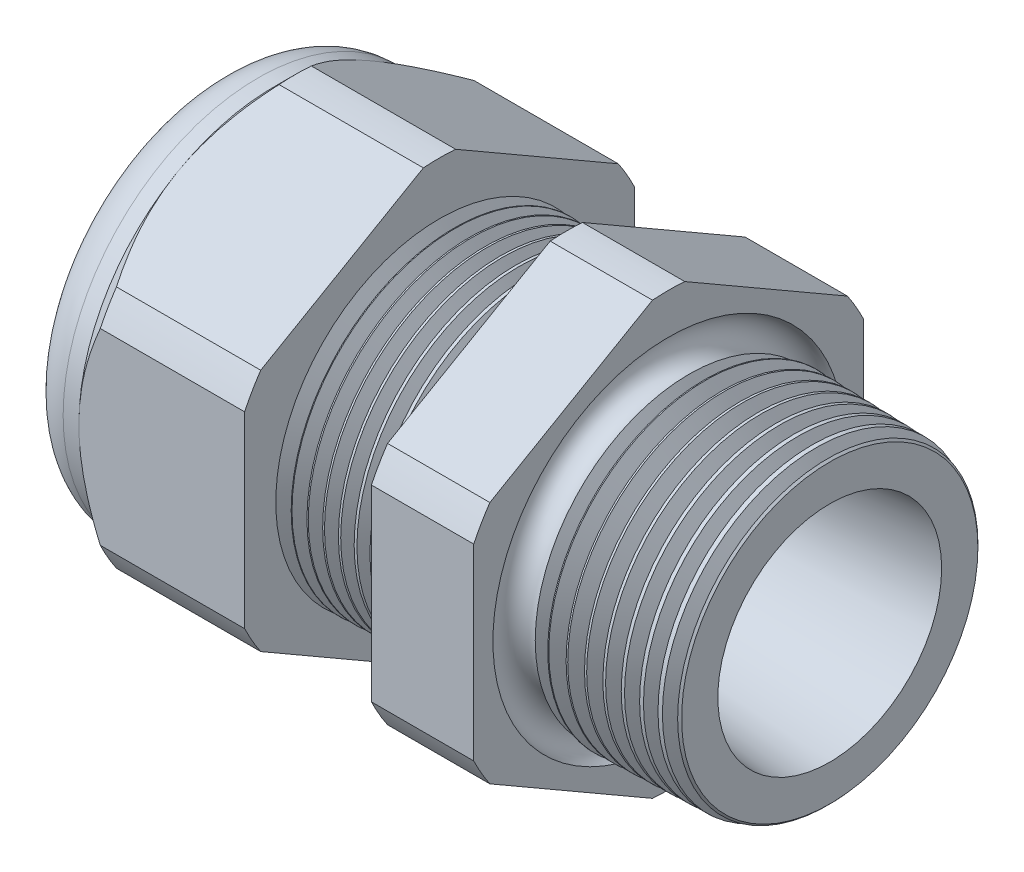
from build123d import *

# Parameters (mm, degrees)
SKETCH12_OUTSIDE_W = 52.432
SKETCH12_OUTSIDE_H = 52.432
CUT_EXTRUDE2_DEPTH = 28.172
FILLET4_R          = 2.032
SKETCH19_OUTSIDE_W = 33.316
SKETCH19_OUTSIDE_H = 35.412
SKETCH19_OUTSIDE_R = 9.525
CUT_EXTRUDE3_DEPTH = 1.999996
CUT_EXTRUDE3_DRAFT = -45
CHAMFER1_SIZE      = 0.260919487
CHAMFER1_SIZE2     = 0.254
SKETCH21_R         = 3.937
PLUG_DEPTH         = 3.81
SKETCH22_R         = 3.683
CUT_EXTRUDE4_DEPTH = 0.508
SKETCH27_R         = 0.889
PLUGHOLES_DEPTH    = 30.464
CIRPATTERN1_COUNT  = 4
LPATTERN1_COUNT    = 8
LPATTERN1_PITCH    = 0.762
LPATTERN2_COUNT    = 9
LPATTERN2_PITCH    = 0.889
SKETCH32_R         = 0.889


with BuildPart() as part:
    # Sketch10 → Revolve2 (revolve)
    with BuildSketch(Plane.XY, mode=Mode.PRIVATE) as revolve2_sk:
        Polygon((-29.972, 3.937), (-19.072, 3.937), (0, 5.469582104), (0, 7.501582104), (-7.874, 7.70777005), (-7.874, 19.05), (-12.874, 19.05), (-12.874, 7.838699658), (-19.072, 8.001), (-19.072, 19.05), (-27.172, 19.05), (-27.172, 9.525), (-29.972, 9.525), align=None)
    revolve(revolve2_sk.sketch.rotate(Axis((0, 0, 0), (-1, 0, 0)), 90), axis=Axis((0, 0, 0), (-1, 0, 0)))  # turned: the seam where the file's is

    # Sketch12 outside → Cut-Extrude2 (cut, through all)
    with BuildSketch(Plane.ZY.offset(27.172)):
        Rectangle(SKETCH12_OUTSIDE_W, SKETCH12_OUTSIDE_H)
        with BuildLine():
            Line((-0.788451287, 10.543310065), (-8.736548713, 5.954473877))
            ThreePointArc((-8.736548713, 5.954473877), (-9.156270088, 5.286375), (-9.525, 4.588836188))
            Line((-9.525, 4.588836188), (-9.525, -4.588836188))
            ThreePointArc((-9.525, -4.588836188), (-9.156270088, -5.286375), (-8.736548713, -5.954473877))
            Line((-8.736548713, -5.954473877), (-0.788451287, -10.543310065))
            ThreePointArc((-0.788451287, -10.543310065), (0, -10.57275), (0.788451287, -10.543310065))
            Line((0.788451287, -10.543310065), (8.736548713, -5.954473877))
            ThreePointArc((8.736548713, -5.954473877), (9.156270088, -5.286375), (9.525, -4.588836188))
            Line((9.525, -4.588836188), (9.525, 4.588836188))
            ThreePointArc((9.525, 4.588836188), (9.156270088, 5.286375), (8.736548713, 5.954473877))
            Line((8.736548713, 5.954473877), (0.788451287, 10.543310065))
            ThreePointArc((0.788451287, 10.543310065), (0, 10.57275), (-0.788451287, 10.543310065))
        make_face(mode=Mode.SUBTRACT)
    extrude(amount=-CUT_EXTRUDE2_DEPTH, mode=Mode.SUBTRACT)

    # Fillet4
    fillet4_edges = [part.edges().sort_by_distance(p)[0] for p in [
        (-29.972, 0, 9.525),
    ]]
    fillet(fillet4_edges, radius=FILLET4_R)


with BuildPart() as cut_extrude3_tool:
    # Sketch19 outside → Cut-Extrude3 (with draft: the straight prism first)
    with BuildSketch(Plane.ZY.offset(27.172)):
        Rectangle(SKETCH19_OUTSIDE_W, SKETCH19_OUTSIDE_H)
        Circle(SKETCH19_OUTSIDE_R, mode=Mode.SUBTRACT)
    extrude(amount=-CUT_EXTRUDE3_DEPTH)
    # Cut-Extrude3: the draft: its side faces are tilted about the plane it starts from
    cut_extrude3_sides = [cut_extrude3_tool.faces().sort_by_distance(p)[0] for p in [
        (-26.172002, -17.706, 0),
        (-26.172002, 0, 16.658),
        (-26.172002, 17.706, 0),
        (-26.172002, 0, -16.658),
        (-26.172002, 0, -9.525),
    ]]
    draft(cut_extrude3_sides, Plane.ZY.offset(27.172), CUT_EXTRUDE3_DRAFT)


with BuildPart() as part_1:
    add(part.part)

    # Cut-Extrude3: cut by cut_extrude3_tool
    add(cut_extrude3_tool.part, mode=Mode.SUBTRACT)

    # Chamfer1
    chamfer1_edges = [part_1.edges().sort_by_distance(p)[0] for p in [
        (0, 0, 7.501582104),
    ]]
    chamfer1_side = [part_1.faces().sort_by_distance(p)[0] for p in [
        (0, 0, 5.681758887),
    ]]
    chamfer(chamfer1_edges, length=CHAMFER1_SIZE, length2=CHAMFER1_SIZE2, reference=chamfer1_side[0])

    # Sketch29 → Cut-Revolve1 (revolve, cut)
    with BuildSketch(Plane.XY, mode=Mode.PRIVATE) as cut_revolve1_sk:
        Polygon((-19.072, 8.001), (-18.339016419, 7.981806149), (-18.722130572, 7.356620673), align=None)
    cut_revolve1 = revolve(cut_revolve1_sk.sketch.rotate(Axis((0, 0, 0), (-1, 0, 0)), 90), axis=Axis((0, 0, 0), (-1, 0, 0)), mode=Mode.SUBTRACT)  # turned: the seam where the file's is

    # LPattern1: Cut-Revolve1 ×8
    with Locations(*[(i * LPATTERN1_PITCH, 0, 0) for i in range(1, LPATTERN1_COUNT)]):
        add(cut_revolve1, mode=Mode.SUBTRACT)

    # Sketch30 → Cut-Revolve2 (revolve, cut)
    with BuildSketch(Plane.XY, mode=Mode.PRIVATE) as cut_revolve2_sk:
        Polygon((-7.874, 7.70777005), (-6.994419703, 7.68473743), (-7.454156686, 6.934514858), align=None)
    cut_revolve2 = revolve(cut_revolve2_sk.sketch.rotate(Axis((0, 0, 0), (-1, 0, 0)), 270), axis=Axis((0, 0, 0), (-1, 0, 0)), mode=Mode.SUBTRACT)  # turned: the seam where the file's is

    # LPattern2: Cut-Revolve2 ×9
    with Locations(*[(i * LPATTERN2_PITCH, 0, 0) for i in range(1, LPATTERN2_COUNT)]):
        add(cut_revolve2, mode=Mode.SUBTRACT)

    # Sketch32 → Cut-Revolve3 (revolve, cut)
    with BuildSketch(Plane.XY, mode=Mode.PRIVATE) as cut_revolve3_sk:
        with Locations((-7.747, 7.70777005)):
            Circle(SKETCH32_R)
    revolve(cut_revolve3_sk.sketch.rotate(Axis((0, 0, 0), (-1, 0, 0)), 270), axis=Axis((0, 0, 0), (-1, 0, 0)), mode=Mode.SUBTRACT)  # turned: the seam where the file's is


with BuildPart() as body_2:
    # Sketch21 → plug (new body)
    with BuildSketch(Plane.ZY.offset(29.972)):
        Circle(SKETCH21_R)
    extrude(amount=-PLUG_DEPTH)

    # Sketch22 → Cut-Extrude4 (cut)
    with BuildSketch(Plane.ZY.offset(29.972)):
        Circle(SKETCH22_R)
    extrude(amount=-CUT_EXTRUDE4_DEPTH, mode=Mode.SUBTRACT)

    # Sketch27 → plugholes (cut, through all)
    with BuildSketch(Plane.ZY.offset(29.464)):
        with Locations((-2.790444, 0)):
            Circle(SKETCH27_R)
    plugholes = extrude(amount=-PLUGHOLES_DEPTH, mode=Mode.SUBTRACT)

    # CirPattern1: plugholes ×4 about axis
    cirpattern1_axis = Axis((0, 0, 0), (1, 0, 0))
    for i in range(1, CIRPATTERN1_COUNT):
        add(plugholes.rotate(cirpattern1_axis, i * 360 / CIRPATTERN1_COUNT), mode=Mode.SUBTRACT)


solid = Compound([part_1.part, body_2.part])
